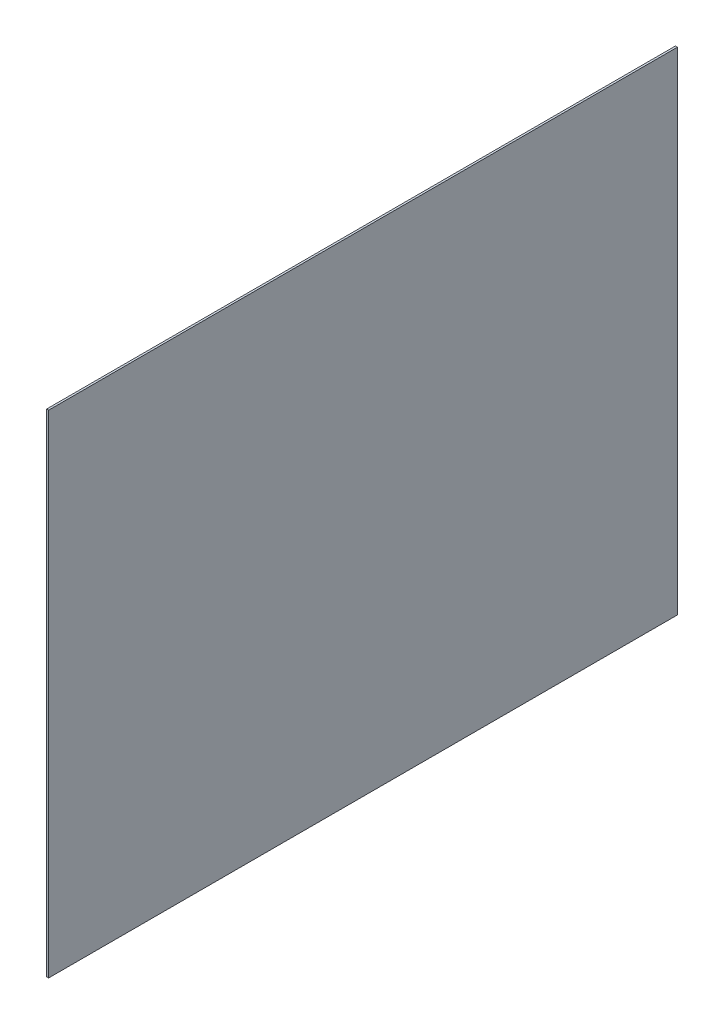
from build123d import *

# Parameters (mm, degrees)
SKETCH1_W           = 7924.8
SKETCH1_H           = 6197.6
BOSS_EXTRUDE1_DEPTH = 25.4


with BuildPart() as part:
    # Sketch1 → Boss-Extrude1 (new body)
    with BuildSketch(Plane(origin=(0, 0, 0), x_dir=(0, 0, -1), z_dir=(1, 0, 0))):
        Rectangle(SKETCH1_W, SKETCH1_H)
    extrude(amount=BOSS_EXTRUDE1_DEPTH)


solid = part.part
